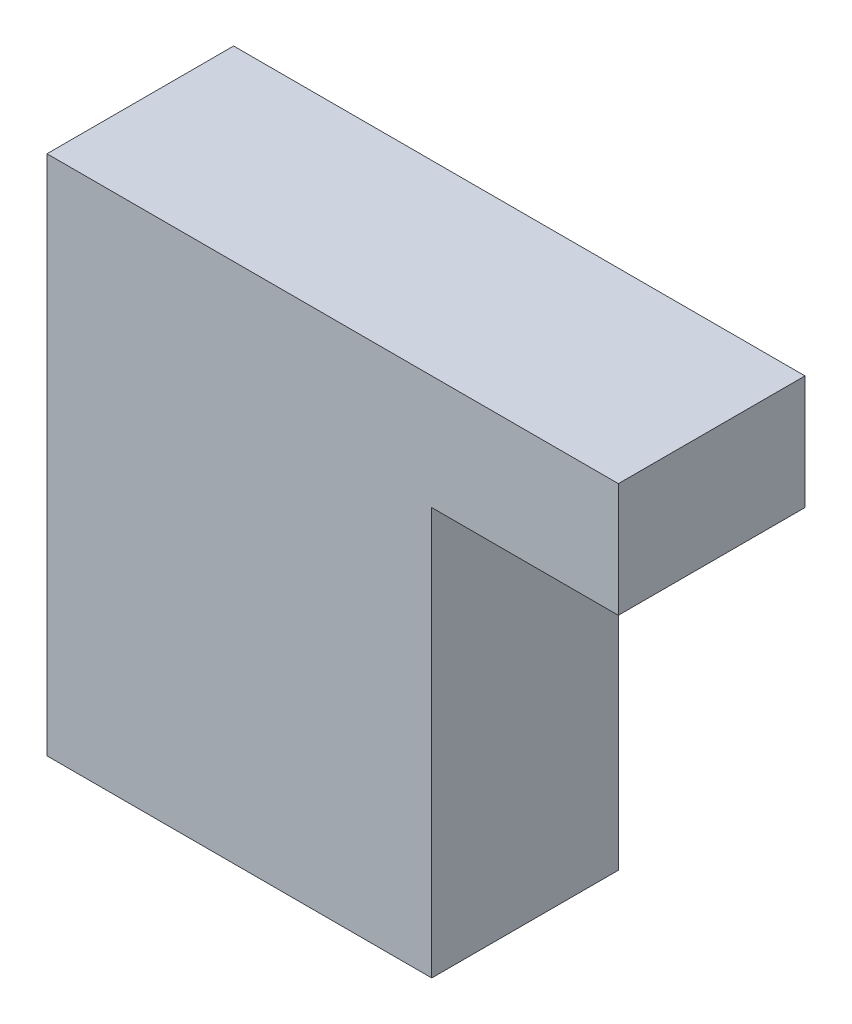
from build123d import *

# Parameters (mm, degrees)
SKIZZE1_W                       = 20.615840772
SKIZZE1_H                       = 27.939889468
AUFSATZ_LINEAR_AUSTRAGEN1_DEPTH = 10
SKIZZE3_W                       = 10
SKIZZE3_H                       = 6.110433848
AUFSATZ_LINEAR_AUSTRAGEN2_DEPTH = 10


with BuildPart() as part:
    # Skizze1 → Aufsatz-Linear austragen1 (new body)
    with BuildSketch(Plane.XY):
        with Locations((10.307920386, -13.969944734)):
            Rectangle(SKIZZE1_W, SKIZZE1_H)
    extrude(amount=AUFSATZ_LINEAR_AUSTRAGEN1_DEPTH)

    # Skizze3 → Aufsatz-Linear austragen2 (add)
    with BuildSketch(Plane(origin=(20.615840772, 0, 0), x_dir=(0, 0, -1), z_dir=(1, 0, 0))):
        with Locations((-5, -3.055216924)):
            Rectangle(SKIZZE3_W, SKIZZE3_H)
    extrude(amount=AUFSATZ_LINEAR_AUSTRAGEN2_DEPTH)


solid = part.part
